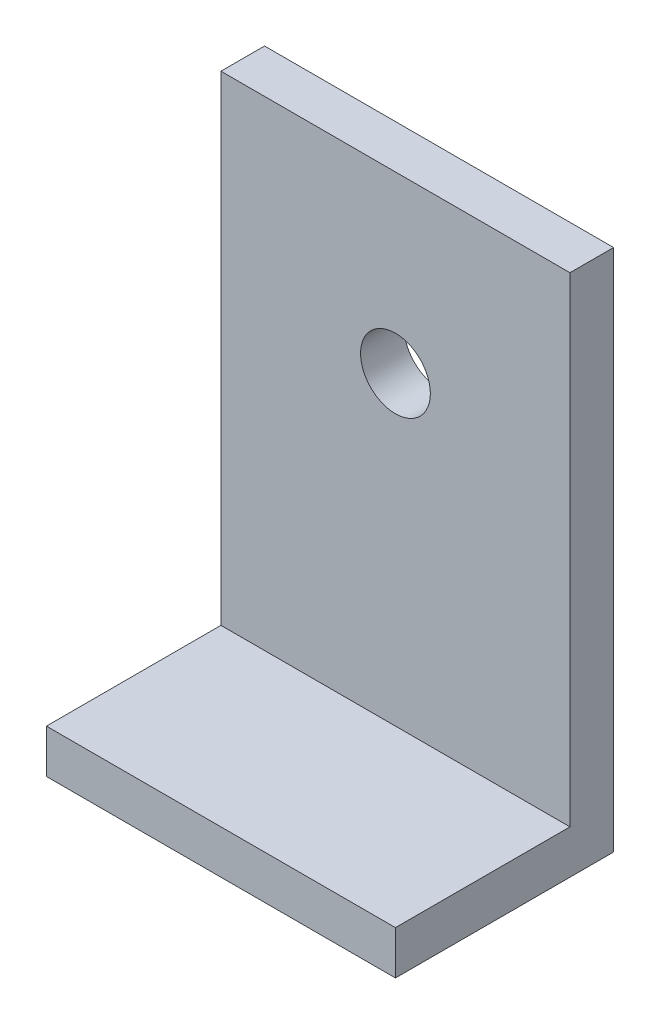
from build123d import *

# Parameters (mm, degrees)
SKETCH1_W           = 40
SKETCH1_H           = 55
BOSS_EXTRUDE1_DEPTH = 5
SKETCH1_3_W         = 40
SKETCH1_3_H         = 5
BOSS_EXTRUDE2_DEPTH = 25
SKETCH2_R           = 4
CUT_EXTRUDE1_DEPTH  = 71.887234394


with BuildPart() as part:
    # Sketch1 → Boss-Extrude1 (new body)
    with BuildSketch(Plane.XY):
        with Locations((20, 27.5)):
            Rectangle(SKETCH1_W, SKETCH1_H)
    extrude(amount=BOSS_EXTRUDE1_DEPTH)

    # Sketch1_3 → Boss-Extrude2 (add)
    with BuildSketch(Plane.XY):
        with Locations((20, -2.5)):
            Rectangle(SKETCH1_3_W, SKETCH1_3_H)
    extrude(amount=BOSS_EXTRUDE2_DEPTH)

    # Sketch2 → Cut-Extrude1 (cut, through all)
    with BuildSketch(Plane.XY.offset(5)):
        with Locations((20, 35)):
            Circle(SKETCH2_R)
    extrude(amount=-CUT_EXTRUDE1_DEPTH, mode=Mode.SUBTRACT)


solid = part.part
